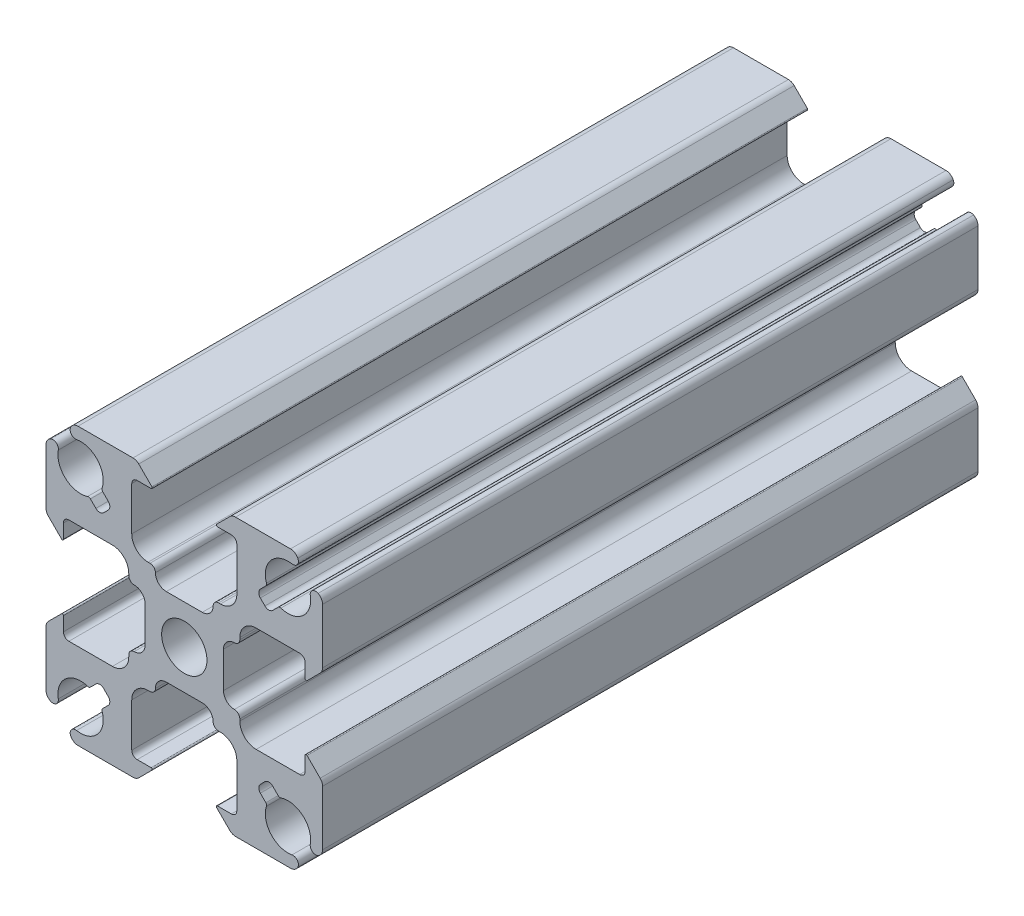
from build123d import *

# Parameters (mm, degrees)
SKETCH1_R           = 2.08
BOSS_EXTRUDE1_DEPTH = 30.098494032


with BuildPart() as part:
    # Sketch1 → Boss-Extrude1 (new body, symmetric)
    with BuildSketch(Plane(origin=(0, 0, 0), x_dir=(-1, 0, 0), z_dir=(0, 0, -1))):
        with BuildLine():
            Line((-7.48853247, 8.61990332), (-6.985643798, 8.117014648))
            ThreePointArc((-6.985643798, 8.117014648), (-6.839197188, 7.763461257), (-6.985643798, 7.409907866))
            Line((-6.985643798, 7.409907866), (-7.409907866, 6.985643798))
            ThreePointArc((-7.409907866, 6.985643798), (-7.763461257, 6.839197188), (-8.117014648, 6.985643798))
            Line((-8.117014648, 6.985643798), (-8.61990332, 7.48853247))
            ThreePointArc((-8.61990332, 7.48853247), (-8.738774884, 7.554957329), (-8.874825936, 7.549228331))
            ThreePointArc((-8.874825936, 7.549228331), (-10.889377278, 7.955008076), (-11.572136222, 9.893284252))
            ThreePointArc((-11.572136222, 9.893284252), (-11.766795458, 10.383720777), (-12.292708824, 10.42656157))
            ThreePointArc((-12.292708824, 10.42656157), (-12.590129525, 10.150252615), (-12.7, 9.759440396))
            Line((-12.7, 9.759440396), (-12.7, 4.710660172))
            ThreePointArc((-12.7, 4.710660172), (-12.642909649, 4.423647598), (-12.480330086, 4.180330086))
            Line((-12.480330086, 4.180330086), (-11.270710678, 2.970710678))
            ThreePointArc((-11.270710678, 2.970710678), (-11.161731657, 2.949033403), (-11.1, 3.041421356))
            Line((-11.1, 3.041421356), (-11.1, 4.325))
            ThreePointArc((-11.1, 4.325), (-10.953553391, 4.678553391), (-10.6, 4.825))
            Line((-10.6, 4.825), (-6.6, 4.825))
            ThreePointArc((-6.6, 4.825), (-5.539339828, 4.385660172), (-5.1, 3.325))
            Line((-5.1, 3.325), (-5.1, 3.15))
            ThreePointArc((-5.1, 3.15), (-4.953553391, 2.796446609), (-4.6, 2.65))
            ThreePointArc((-4.6, 2.65), (-3.892893219, 2.357106781), (-3.6, 1.65))
            Line((-3.6, 1.65), (-3.6, -1.65))
            ThreePointArc((-3.6, -1.65), (-3.892893219, -2.357106781), (-4.6, -2.65))
            ThreePointArc((-4.6, -2.65), (-4.953553391, -2.796446609), (-5.1, -3.15))
            Line((-5.1, -3.15), (-5.1, -3.325))
            ThreePointArc((-5.1, -3.325), (-5.539339828, -4.385660172), (-6.6, -4.825))
            Line((-6.6, -4.825), (-10.6, -4.825))
            ThreePointArc((-10.6, -4.825), (-10.953553391, -4.678553391), (-11.1, -4.325))
            Line((-11.1, -4.325), (-11.1, -3.041421356))
            ThreePointArc((-11.1, -3.041421356), (-11.161731657, -2.949033403), (-11.270710678, -2.970710678))
            Line((-11.270710678, -2.970710678), (-12.480330086, -4.180330086))
            ThreePointArc((-12.480330086, -4.180330086), (-12.642909649, -4.423647598), (-12.7, -4.710660172))
            Line((-12.7, -4.710660172), (-12.7, -9.759440396))
            ThreePointArc((-12.7, -9.759440396), (-12.590129525, -10.150252615), (-12.292708824, -10.42656157))
            ThreePointArc((-12.292708824, -10.42656157), (-11.766795458, -10.383720777), (-11.572136222, -9.893284252))
            ThreePointArc((-11.572136222, -9.893284252), (-10.889377278, -7.955008076), (-8.874825936, -7.549228331))
            ThreePointArc((-8.874825936, -7.549228331), (-8.738774884, -7.554957329), (-8.61990332, -7.48853247))
            Line((-8.61990332, -7.48853247), (-8.117014648, -6.985643798))
            ThreePointArc((-8.117014648, -6.985643798), (-7.763461257, -6.839197188), (-7.409907866, -6.985643798))
            Line((-7.409907866, -6.985643798), (-6.985643798, -7.409907866))
            ThreePointArc((-6.985643798, -7.409907866), (-6.839197188, -7.763461257), (-6.985643798, -8.117014648))
            Line((-6.985643798, -8.117014648), (-7.48853247, -8.61990332))
            ThreePointArc((-7.48853247, -8.61990332), (-7.554957329, -8.738774884), (-7.549228331, -8.874825936))
            ThreePointArc((-7.549228331, -8.874825936), (-7.955008076, -10.889377278), (-9.893284252, -11.572136222))
            ThreePointArc((-9.893284252, -11.572136222), (-10.383720777, -11.766795458), (-10.42656157, -12.292708824))
            ThreePointArc((-10.42656157, -12.292708824), (-10.150252615, -12.590129525), (-9.759440396, -12.7))
            Line((-9.759440396, -12.7), (-4.710660172, -12.7))
            ThreePointArc((-4.710660172, -12.7), (-4.423647598, -12.642909649), (-4.180330086, -12.480330086))
            Line((-4.180330086, -12.480330086), (-2.970710678, -11.270710678))
            ThreePointArc((-2.970710678, -11.270710678), (-2.949033403, -11.161731657), (-3.041421356, -11.1))
            Line((-3.041421356, -11.1), (-4.325, -11.1))
            ThreePointArc((-4.325, -11.1), (-4.678553391, -10.953553391), (-4.825, -10.6))
            Line((-4.825, -10.6), (-4.825, -6.6))
            ThreePointArc((-4.825, -6.6), (-4.385660172, -5.539339828), (-3.325, -5.1))
            Line((-3.325, -5.1), (-3.15, -5.1))
            ThreePointArc((-3.15, -5.1), (-2.796446609, -4.953553391), (-2.65, -4.6))
            ThreePointArc((-2.65, -4.6), (-2.357106781, -3.892893219), (-1.65, -3.6))
            Line((-1.65, -3.6), (1.65, -3.6))
            ThreePointArc((1.65, -3.6), (2.357106781, -3.892893219), (2.65, -4.6))
            ThreePointArc((2.65, -4.6), (2.796446609, -4.953553391), (3.15, -5.1))
            Line((3.15, -5.1), (3.325, -5.1))
            ThreePointArc((3.325, -5.1), (4.385660172, -5.539339828), (4.825, -6.6))
            Line((4.825, -6.6), (4.825, -10.6))
            ThreePointArc((4.825, -10.6), (4.678553391, -10.953553391), (4.325, -11.1))
            Line((4.325, -11.1), (3.041421356, -11.1))
            ThreePointArc((3.041421356, -11.1), (2.949033403, -11.161731657), (2.970710678, -11.270710678))
            Line((2.970710678, -11.270710678), (4.180330086, -12.480330086))
            ThreePointArc((4.180330086, -12.480330086), (4.423647598, -12.642909649), (4.710660172, -12.7))
            Line((4.710660172, -12.7), (9.759440396, -12.7))
            ThreePointArc((9.759440396, -12.7), (10.150252615, -12.590129525), (10.42656157, -12.292708824))
            ThreePointArc((10.42656157, -12.292708824), (10.383720777, -11.766795458), (9.893284252, -11.572136222))
            ThreePointArc((9.893284252, -11.572136222), (7.955008076, -10.889377278), (7.549228331, -8.874825936))
            ThreePointArc((7.549228331, -8.874825936), (7.554957329, -8.738774884), (7.48853247, -8.61990332))
            Line((7.48853247, -8.61990332), (6.985643798, -8.117014648))
            ThreePointArc((6.985643798, -8.117014648), (6.839197188, -7.763461257), (6.985643798, -7.409907866))
            Line((6.985643798, -7.409907866), (7.409907866, -6.985643798))
            ThreePointArc((7.409907866, -6.985643798), (7.763461257, -6.839197188), (8.117014648, -6.985643798))
            Line((8.117014648, -6.985643798), (8.61990332, -7.48853247))
            ThreePointArc((8.61990332, -7.48853247), (8.738774884, -7.554957329), (8.874825936, -7.549228331))
            ThreePointArc((8.874825936, -7.549228331), (10.889377278, -7.955008076), (11.572136222, -9.893284252))
            ThreePointArc((11.572136222, -9.893284252), (11.766795458, -10.383720777), (12.292708824, -10.42656157))
            ThreePointArc((12.292708824, -10.42656157), (12.590129525, -10.150252615), (12.7, -9.759440396))
            Line((12.7, -9.759440396), (12.7, -4.710660172))
            ThreePointArc((12.7, -4.710660172), (12.642909649, -4.423647598), (12.480330086, -4.180330086))
            Line((12.480330086, -4.180330086), (11.270710678, -2.970710678))
            ThreePointArc((11.270710678, -2.970710678), (11.161731657, -2.949033403), (11.1, -3.041421356))
            Line((11.1, -3.041421356), (11.1, -4.325))
            ThreePointArc((11.1, -4.325), (10.953553391, -4.678553391), (10.6, -4.825))
            Line((10.6, -4.825), (6.6, -4.825))
            ThreePointArc((6.6, -4.825), (5.539339828, -4.385660172), (5.1, -3.325))
            Line((5.1, -3.325), (5.1, -3.15))
            ThreePointArc((5.1, -3.15), (4.953553391, -2.796446609), (4.6, -2.65))
            ThreePointArc((4.6, -2.65), (3.892893219, -2.357106781), (3.6, -1.65))
            Line((3.6, -1.65), (3.6, 1.65))
            ThreePointArc((3.6, 1.65), (3.892893219, 2.357106781), (4.6, 2.65))
            ThreePointArc((4.6, 2.65), (4.953553391, 2.796446609), (5.1, 3.15))
            Line((5.1, 3.15), (5.1, 3.325))
            ThreePointArc((5.1, 3.325), (5.539339828, 4.385660172), (6.6, 4.825))
            Line((6.6, 4.825), (10.6, 4.825))
            ThreePointArc((10.6, 4.825), (10.953553391, 4.678553391), (11.1, 4.325))
            Line((11.1, 4.325), (11.1, 3.041421356))
            ThreePointArc((11.1, 3.041421356), (11.161731657, 2.949033403), (11.270710678, 2.970710678))
            Line((11.270710678, 2.970710678), (12.480330086, 4.180330086))
            ThreePointArc((12.480330086, 4.180330086), (12.642909649, 4.423647598), (12.7, 4.710660172))
            Line((12.7, 4.710660172), (12.7, 9.759440396))
            ThreePointArc((12.7, 9.759440396), (12.590129525, 10.150252615), (12.292708824, 10.42656157))
            ThreePointArc((12.292708824, 10.42656157), (11.766795458, 10.383720777), (11.572136222, 9.893284252))
            ThreePointArc((11.572136222, 9.893284252), (10.889377278, 7.955008076), (8.874825936, 7.549228331))
            ThreePointArc((8.874825936, 7.549228331), (8.738774884, 7.554957329), (8.61990332, 7.48853247))
            Line((8.61990332, 7.48853247), (8.117014648, 6.985643798))
            ThreePointArc((8.117014648, 6.985643798), (7.763461257, 6.839197188), (7.409907866, 6.985643798))
            Line((7.409907866, 6.985643798), (6.985643798, 7.409907866))
            ThreePointArc((6.985643798, 7.409907866), (6.839197188, 7.763461257), (6.985643798, 8.117014648))
            Line((6.985643798, 8.117014648), (7.48853247, 8.61990332))
            ThreePointArc((7.48853247, 8.61990332), (7.554957329, 8.738774884), (7.549228331, 8.874825936))
            ThreePointArc((7.549228331, 8.874825936), (7.955008076, 10.889377278), (9.893284252, 11.572136222))
            ThreePointArc((9.893284252, 11.572136222), (10.383720777, 11.766795458), (10.42656157, 12.292708824))
            ThreePointArc((10.42656157, 12.292708824), (10.150252615, 12.590129525), (9.759440396, 12.7))
            Line((9.759440396, 12.7), (4.710660172, 12.7))
            ThreePointArc((4.710660172, 12.7), (4.423647598, 12.642909649), (4.180330086, 12.480330086))
            Line((4.180330086, 12.480330086), (2.970710678, 11.270710678))
            ThreePointArc((2.970710678, 11.270710678), (2.949033403, 11.161731657), (3.041421356, 11.1))
            Line((3.041421356, 11.1), (4.325, 11.1))
            ThreePointArc((4.325, 11.1), (4.678553391, 10.953553391), (4.825, 10.6))
            Line((4.825, 10.6), (4.825, 6.6))
            ThreePointArc((4.825, 6.6), (4.385660172, 5.539339828), (3.325, 5.1))
            Line((3.325, 5.1), (3.15, 5.1))
            ThreePointArc((3.15, 5.1), (2.796446609, 4.953553391), (2.65, 4.6))
            ThreePointArc((2.65, 4.6), (2.357106781, 3.892893219), (1.65, 3.6))
            Line((1.65, 3.6), (-1.65, 3.6))
            ThreePointArc((-1.65, 3.6), (-2.357106781, 3.892893219), (-2.65, 4.6))
            ThreePointArc((-2.65, 4.6), (-2.796446609, 4.953553391), (-3.15, 5.1))
            Line((-3.15, 5.1), (-3.325, 5.1))
            ThreePointArc((-3.325, 5.1), (-4.385660172, 5.539339828), (-4.825, 6.6))
            Line((-4.825, 6.6), (-4.825, 10.6))
            ThreePointArc((-4.825, 10.6), (-4.678553391, 10.953553391), (-4.325, 11.1))
            Line((-4.325, 11.1), (-3.041421356, 11.1))
            ThreePointArc((-3.041421356, 11.1), (-2.949033403, 11.161731657), (-2.970710678, 11.270710678))
            Line((-2.970710678, 11.270710678), (-4.180330086, 12.480330086))
            ThreePointArc((-4.180330086, 12.480330086), (-4.423647598, 12.642909649), (-4.710660172, 12.7))
            Line((-4.710660172, 12.7), (-9.759440396, 12.7))
            ThreePointArc((-9.759440396, 12.7), (-10.150252615, 12.590129525), (-10.42656157, 12.292708824))
            ThreePointArc((-10.42656157, 12.292708824), (-10.383720777, 11.766795458), (-9.893284252, 11.572136222))
            ThreePointArc((-9.893284252, 11.572136222), (-7.955008076, 10.889377278), (-7.549228331, 8.874825936))
            ThreePointArc((-7.549228331, 8.874825936), (-7.554957329, 8.738774884), (-7.48853247, 8.61990332))
        make_face()
        Circle(SKETCH1_R, mode=Mode.SUBTRACT)
    extrude(amount=BOSS_EXTRUDE1_DEPTH, both=True)


solid = part.part
